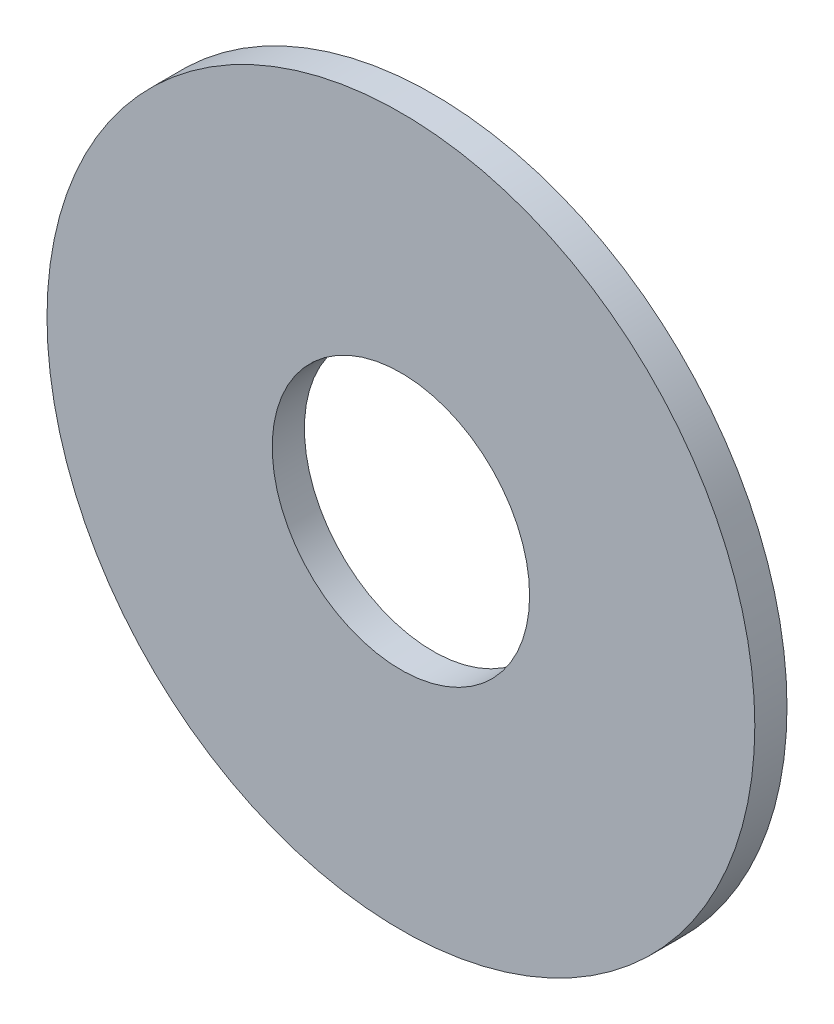
from build123d import *

# Parameters (mm, degrees)
ESQUISSE1_R      = 11
ESQUISSE1_R_2    = 4
EXTRUSION1_DEPTH = 1


with BuildPart() as part:
    # Esquisse1 → Extrusion1 (new body)
    with BuildSketch(Plane.XY):
        Circle(ESQUISSE1_R)
        Circle(ESQUISSE1_R_2, mode=Mode.SUBTRACT)
    extrude(amount=EXTRUSION1_DEPTH)


solid = part.part
